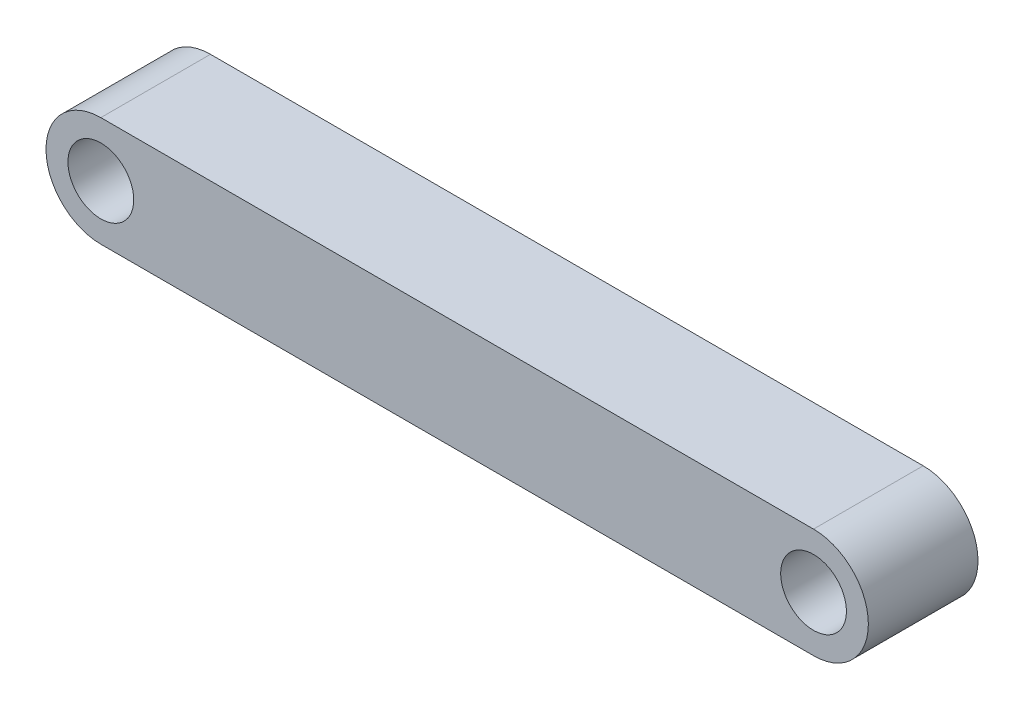
from build123d import *

# Parameters (mm, degrees)
SKETCH1_R           = 1.5
BOSS_EXTRUDE1_DEPTH = 5


with BuildPart() as part:
    # Sketch1 → Boss-Extrude1 (new body)
    with BuildSketch(Plane.XY):
        with BuildLine():
            Line((-26.333333333, 2.5), (6.166666667, 2.5))
            ThreePointArc((6.166666667, 2.5), (8.666666667, 0), (6.166666667, -2.5))
            Line((6.166666667, -2.5), (-26.333333333, -2.5))
            ThreePointArc((-26.333333333, -2.5), (-28.833333333, 0), (-26.333333333, 2.5))
        make_face()
        with Locations((-26.333333333, 0)):
            Circle(SKETCH1_R, mode=Mode.SUBTRACT)
        with Locations((6.166666667, 0)):
            Circle(SKETCH1_R, mode=Mode.SUBTRACT)
    extrude(amount=BOSS_EXTRUDE1_DEPTH)


solid = part.part
